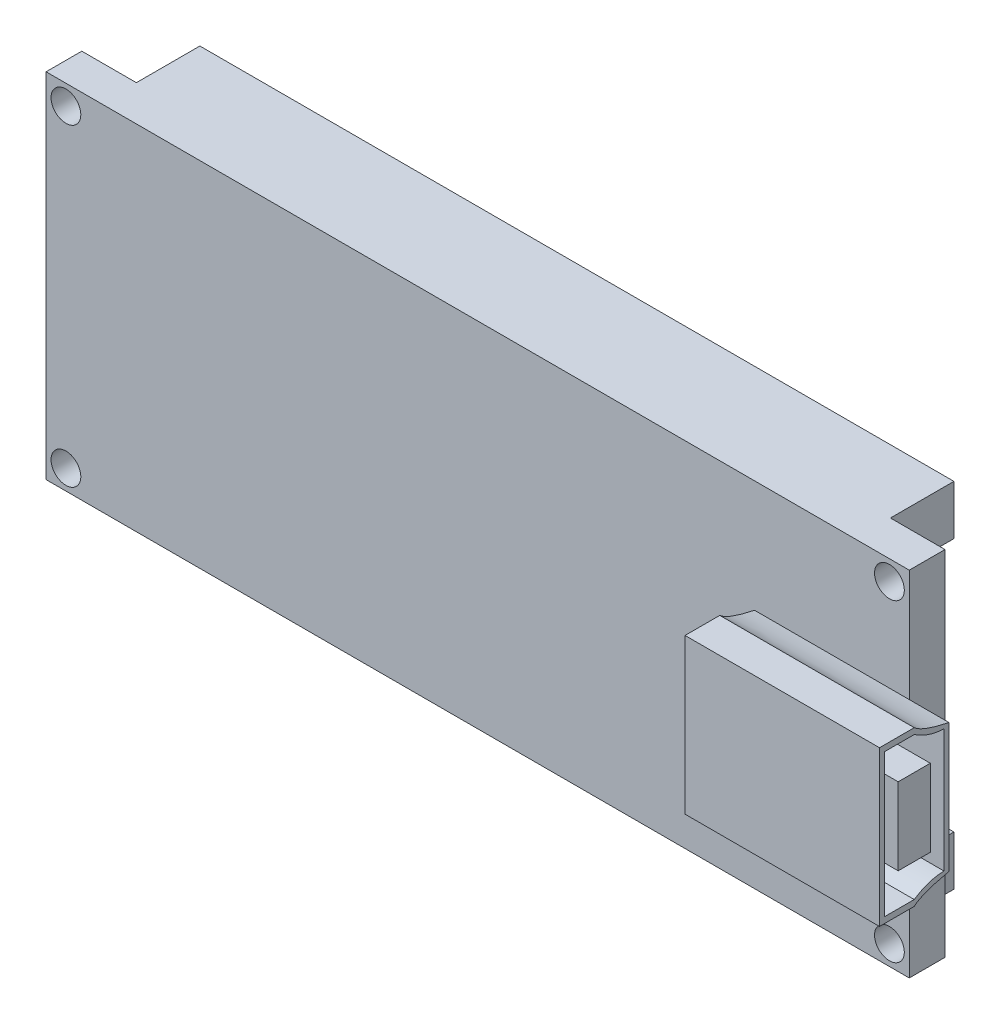
from build123d import *

# Parameters (mm, degrees)
SKETCH1_W           = 43.5
SKETCH1_H           = 17.8
SKETCH1_R           = 0.75
BOSS_EXTRUDE1_DEPTH = 1.8
SKETCH2_W           = 9.8
SKETCH2_H           = 7.8
BOSS_EXTRUDE2_DEPTH = 3.5
CUT_EXTRUDE1_DEPTH  = 46.5
SKETCH4_W           = 1.61922946
SKETCH4_H           = 3.886150706
CUT_EXTRUDE2_DEPTH  = 8.5
SKETCH5_W           = 38
SKETCH5_H           = 2.5
BOSS_EXTRUDE3_DEPTH = 3.2


with BuildPart() as part:
    # Sketch1 → Boss-Extrude1 (new body)
    with BuildSketch(Plane.XY):
        Rectangle(SKETCH1_W, SKETCH1_H)
        with Locations((20.75, 7.9)):
            Circle(SKETCH1_R, mode=Mode.SUBTRACT)
        with Locations((-20.75, 7.9)):
            Circle(SKETCH1_R, mode=Mode.SUBTRACT)
        with Locations((20.75, -7.9)):
            Circle(SKETCH1_R, mode=Mode.SUBTRACT)
        with Locations((-20.75, -7.9)):
            Circle(SKETCH1_R, mode=Mode.SUBTRACT)
    extrude(amount=BOSS_EXTRUDE1_DEPTH)

    # Sketch2 → Boss-Extrude2 (add)
    with BuildSketch(Plane.XY.offset(1.8)):
        with Locations((18.85, 0)):
            Rectangle(SKETCH2_W, SKETCH2_H)
    extrude(amount=BOSS_EXTRUDE2_DEPTH)

    # Sketch3 → Cut-Extrude1 (cut, through all)
    with BuildSketch(Plane(origin=(23.75, 0, 0), x_dir=(0, 0, -1), z_dir=(1, 0, 0))):
        with BuildLine():
            Line((-3.55, 3.9), (-1.8, 3.9))
            Line((-1.8, 3.9), (-1.8, 3.25))
            add(Edge.make_bspline(
                [(-1.8, 3.25), (-3.138543339, 3.528152874), (-3.55, 3.9)],
                knots=[0, 0, 0, 0.396074417, 0.396074417, 0.396074417], degree=2))
        make_face()
        with BuildLine():
            Line((-3.55, -3.9), (-1.8, -3.9))
            Line((-1.8, -3.9), (-1.8, -3.25))
            add(Edge.make_bspline(
                [(-1.8, -3.25), (-3.138543339, -3.528152874), (-3.55, -3.9)],
                knots=[0, 0, 0, 0.396074417, 0.396074417, 0.396074417], degree=2))
        make_face()
    extrude(amount=-CUT_EXTRUDE1_DEPTH, mode=Mode.SUBTRACT)

    # Sketch4 → Cut-Extrude2 (cut)
    with BuildSketch(Plane(origin=(23.75, 0, 0), x_dir=(0, 0, -1), z_dir=(1, 0, 0))):
        with BuildLine():
            Line((-3.55, -3.6), (-5.05, -3.6))
            Line((-5.05, -3.6), (-5.05, 3.6))
            Line((-5.05, 3.6), (-3.55, 3.6))
            add(Edge.make_bspline(
                [(-3.55, 3.6), (-2.837497732, 3.119257632), (-2.05, 3.105849487)],
                knots=[0, 0, 0, 0.945732544, 0.945732544, 0.945732544], degree=2))
            Line((-2.05, 3.105849487), (-2.05, -3.105849487))
            add(Edge.make_bspline(
                [(-3.55, -3.6), (-2.837497732, -3.119257632), (-2.05, -3.105849487)],
                knots=[0, 0, 0, 0.945732544, 0.945732544, 0.945732544], degree=2))
        make_face()
        with Locations((-3.55, 0)):
            Rectangle(SKETCH4_W, SKETCH4_H, mode=Mode.SUBTRACT)
    extrude(amount=-CUT_EXTRUDE2_DEPTH, mode=Mode.SUBTRACT)

    # Sketch5 → Boss-Extrude3 (add)
    with BuildSketch(Plane(origin=(0, 0, 0), x_dir=(-1, 0, 0), z_dir=(0, 0, -1))):
        with Locations((0, 7.65)):
            Rectangle(SKETCH5_W, SKETCH5_H)
        with Locations((0, -7.65)):
            Rectangle(SKETCH5_W, SKETCH5_H)
    extrude(amount=BOSS_EXTRUDE3_DEPTH)


solid = part.part
